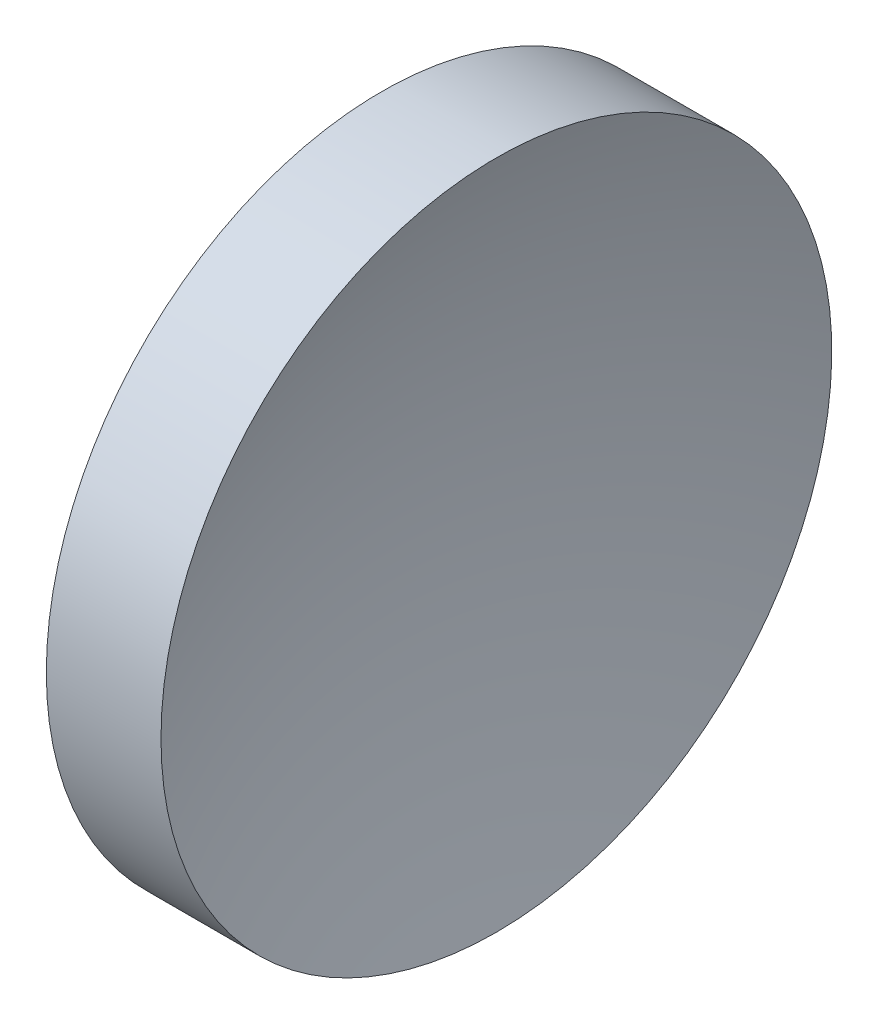
from build123d import *


with BuildPart() as part:
    # 草图1 → 旋转1 (revolve)
    with BuildSketch(Plane.XY, mode=Mode.PRIVATE) as revolve_1_sk:
        with BuildLine():
            Line((119.506834179, 71.193989087), (119.506834179, 83.893989087))
            Line((119.506834179, 83.893989087), (123.849203475, 83.893989087))
            ThreePointArc((123.849203475, 83.893989087), (122.097323663, 77.651091647), (121.506834179, 71.193989087))
            Line((121.506834179, 71.193989087), (119.506834179, 71.193989087))
        make_face()
    revolve(revolve_1_sk.sketch.rotate(Axis((111.955229758, 71.193989087, 0), (1, 0, 0)), 180), axis=Axis((111.955229758, 71.193989087, 0), (1, 0, 0)))  # turned: the seam where the file's is


solid = part.part
